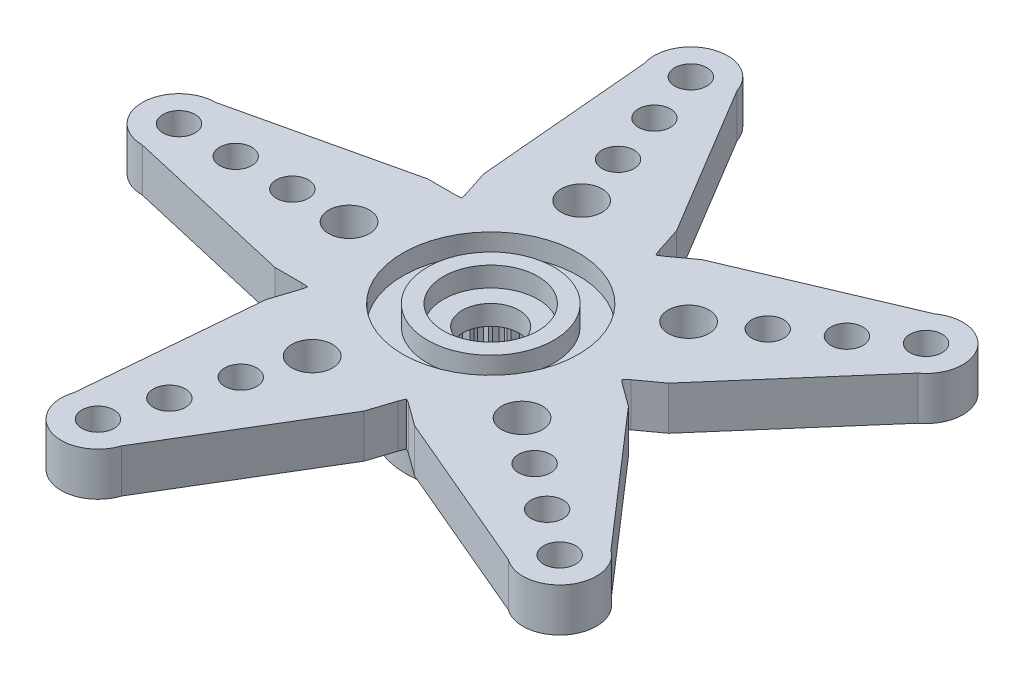
from build123d import *

# Parameters (mm, degrees)
IZIM1_R                     = 4.45
Y_KSEKLIK_EKSTR_ZYON1_DEPTH = 5.6
IZIM2_R                     = 0.85
IZIM2_R_2                   = 1.08184978
Y_KSEKLIK_EKSTR_ZYON2_DEPTH = 2.3
DAIRESEL_KAPLAMA1_COUNT     = 5
IZIM3_R                     = 2.5
KES_EKSTR_ZYON1_DEPTH       = 1.05
IZIM4_R                     = 4.65
IZIM4_R_2                   = 3.35
KES_EKSTR_ZYON2_DEPTH       = 1.05
IZIM5_R                     = 1.5
KES_EKSTR_ZYON3_DEPTH       = 7.05
IZIM6_R                     = 2.68
KES_EKSTR_ZYON4_DEPTH       = 3.5
KES_EKSTR_ZYON5_DEPTH       = 3.5
DAIRESEL_KAPLAMA2_COUNT     = 24


with BuildPart() as part:
    # Çizim1 → Yükseklik-Ekstrüzyon1 (new body)
    with BuildSketch(Plane(origin=(0, 0, 0), x_dir=(1, 0, 0), z_dir=(0, 1, 0))):
        with Locations(Location((0, 0, 0), (0, 0, 270))):
            Circle(IZIM1_R)
    extrude(amount=Y_KSEKLIK_EKSTR_ZYON1_DEPTH)

    # Çizim2 → Yükseklik-Ekstrüzyon2 (add)
    with BuildSketch(Plane(origin=(0, 5.6, 0), x_dir=(1, 0, 0), z_dir=(0, 1, 0))):
        with BuildLine():
            Line((0, 4.69), (0, -4.69))
            Line((0, -4.69), (-4.520042194, -4.69))
            Line((-4.520042194, -4.69), (-4.783580891, -4.426461303))
            ThreePointArc((-4.783580891, -4.426461303), (-5.337293558, -4.147310093), (-5.949896194, -4.051179314))
            Line((-5.949896194, -4.051179314), (-7.379896194, -4.051179314))
            Line((-7.379896194, -4.051179314), (-16.5, -1.945637445))
            ThreePointArc((-16.5, -1.945637445), (-18.445637445, 0), (-16.5, 1.945637445))
            Line((-16.5, 1.945637445), (-7.379896194, 4.051179314))
            Line((-7.379896194, 4.051179314), (-5.949896194, 4.051179314))
            ThreePointArc((-5.949896194, 4.051179314), (-5.337293558, 4.147310093), (-4.783580891, 4.426461303))
            Line((-4.783580891, 4.426461303), (-4.520042194, 4.69))
            Line((-4.520042194, 4.69), (0, 4.69))
        make_face()
        with Locations(Location((-16.5, 0, 0), (0, 0, 270))):
            Circle(IZIM2_R, mode=Mode.SUBTRACT)
        with Locations(Location((-13.5, 0, 0), (0, 0, 270))):
            Circle(IZIM2_R, mode=Mode.SUBTRACT)
        with Locations(Location((-10.5, 0, 0), (0, 0, 270))):
            Circle(IZIM2_R, mode=Mode.SUBTRACT)
        with Locations(Location((-7.5, 0, 0), (0, 0, 270))):
            Circle(IZIM2_R_2, mode=Mode.SUBTRACT)
    y_kseklik_ekstr_zyon2 = extrude(amount=-Y_KSEKLIK_EKSTR_ZYON2_DEPTH)

    # Dairesel Kaplama1: Yükseklik-Ekstrüzyon2 ×5 about axis
    dairesel_kaplama1_axis = Axis((0, 0, 0), (0, 1, 0))
    for i in range(1, DAIRESEL_KAPLAMA1_COUNT):
        add(y_kseklik_ekstr_zyon2.rotate(dairesel_kaplama1_axis, i * 360 / DAIRESEL_KAPLAMA1_COUNT))

    # Çizim3 → Kes-Ekstrüzyon1 (cut)
    with BuildSketch(Plane(origin=(0, 5.6, 0), x_dir=(1, 0, 0), z_dir=(0, 1, 0))):
        with Locations(Location((0, 0, 0), (0, 0, 270))):
            Circle(IZIM3_R)
    extrude(amount=-KES_EKSTR_ZYON1_DEPTH, mode=Mode.SUBTRACT)

    # Çizim4 → Kes-Ekstrüzyon2 (cut)
    with BuildSketch(Plane(origin=(0, 4.55, 0), x_dir=(1, 0, 0), z_dir=(0, 1, 0))):
        with Locations(Location((0, 0, 0), (0, 0, 270))):
            Circle(IZIM4_R)
        with Locations(Location((0, 0, 0), (0, 0, 270))):
            Circle(IZIM4_R_2, mode=Mode.SUBTRACT)
    extrude(amount=KES_EKSTR_ZYON2_DEPTH, mode=Mode.SUBTRACT)

    # Çizim5 → Kes-Ekstrüzyon3 (cut)
    with BuildSketch(Plane(origin=(0, 4.55, 0), x_dir=(1, 0, 0), z_dir=(0, 1, 0))):
        with Locations(Location((0, 0, 0), (0, 0, 270))):
            Circle(IZIM5_R)
    extrude(amount=-KES_EKSTR_ZYON3_DEPTH, mode=Mode.SUBTRACT)

    # Çizim6 → Kes-Ekstrüzyon4 (cut)
    with BuildSketch(Plane.XZ):
        with Locations(Location((0, 0, 0), (0, 0, 270))):
            Circle(IZIM6_R)
    extrude(amount=-KES_EKSTR_ZYON4_DEPTH, mode=Mode.SUBTRACT)

    # Çizim7 → Kes-Ekstrüzyon5 (cut)
    with BuildSketch(Plane.XZ.offset(-3.5)):
        with BuildLine():
            Line((-2.357417444, 1.923535533), (-2.484485613, 1.756341991))
            Line((-2.484485613, 1.756341991), (-2.274980692, 1.416637869))
            ThreePointArc((-2.274980692, 1.416637869), (-2.117608163, 1.642600277), (-1.937879889, 1.851221633))
            Line((-1.937879889, 1.851221633), (-2.357417444, 1.923535533))
        make_face()
    kes_ekstr_zyon5 = extrude(amount=KES_EKSTR_ZYON5_DEPTH, mode=Mode.SUBTRACT)

    # Dairesel Kaplama2: Kes-Ekstrüzyon5 ×24 about axis
    dairesel_kaplama2_axis = Axis((0, 0, 0), (0, 1, 0))
    for i in range(1, DAIRESEL_KAPLAMA2_COUNT):
        add(kes_ekstr_zyon5.rotate(dairesel_kaplama2_axis, i * 360 / DAIRESEL_KAPLAMA2_COUNT), mode=Mode.SUBTRACT)


solid = part.part
